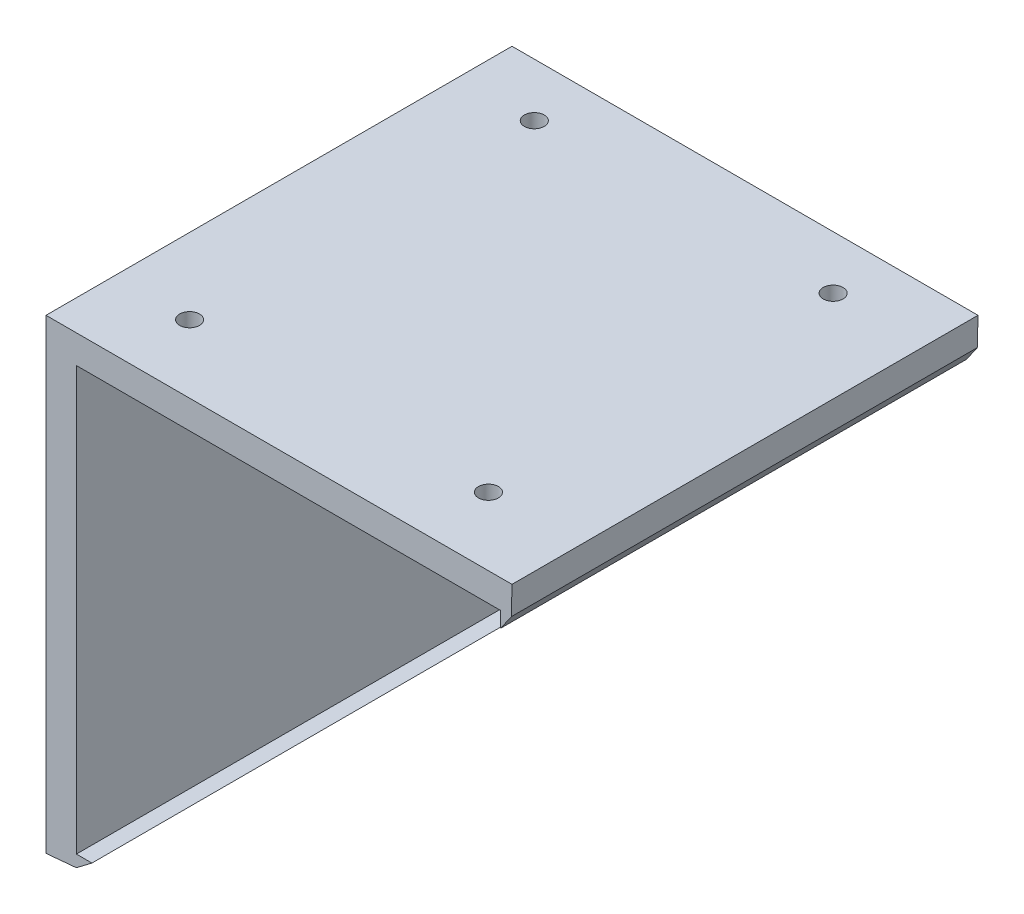
from build123d import *

# Parameters (mm, degrees)
EXTRUDE_1_DEPTH     = 30
SKETCH_2_R          = 0.64072886
CUT_EXTRUDE_2_DEPTH = 7


with BuildPart() as part:
    # 草图1 → 凸台-拉伸1 (new body)
    with BuildSketch(Plane.XY):
        Polygon((28.041755138, 1.822698956), (-1.958244862, 1.822698956), (-1.958244862, -28.177301044), (0, -28), (1, -27.237055845), (0, -27.237055845), (0, 0), (27.305301665, 0), (27.305301665, -1), (28, 0), align=None)
    extrude(amount=EXTRUDE_1_DEPTH)

    # 草图2 → 切除-拉伸2 (cut)
    with BuildSketch(Plane(origin=(0, 0, 0), x_dir=(1, 0, 0), z_dir=(0, 1, 0))):
        with Locations((2.910195006, -3.432793696)):
            Circle(SKETCH_2_R)
        with Locations((2.910195006, -25.623781676)):
            Circle(SKETCH_2_R)
        with Locations((22.147853718, -3.432793696)):
            Circle(SKETCH_2_R)
        with Locations((22.147853718, -25.623781676)):
            Circle(SKETCH_2_R)
    extrude(amount=CUT_EXTRUDE_2_DEPTH, mode=Mode.SUBTRACT)


solid = part.part
